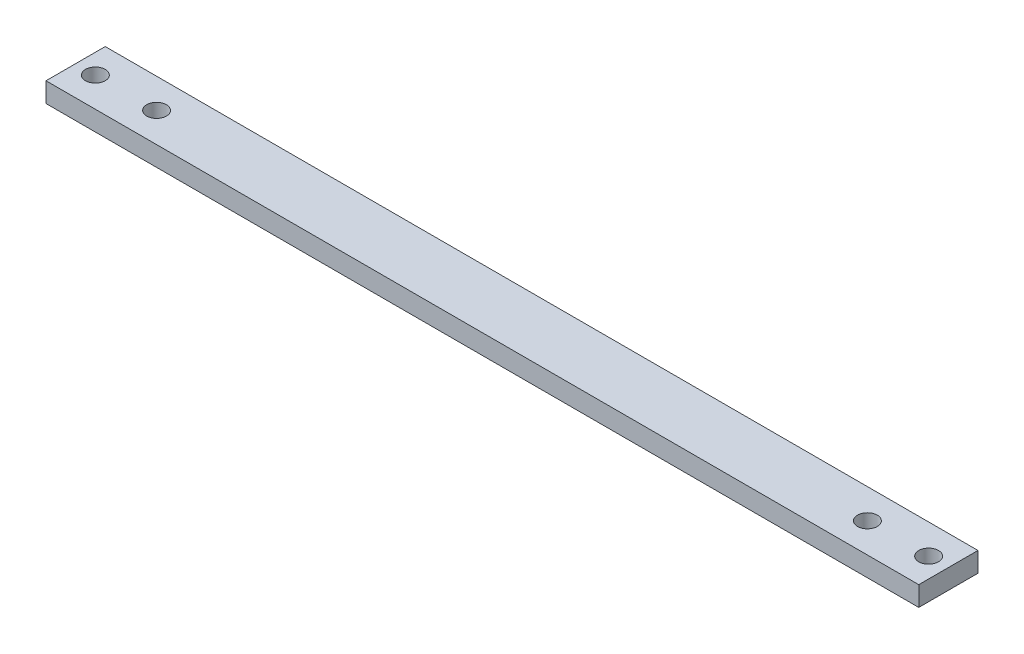
from build123d import *

# Parameters (mm, degrees)
SKETCH1_W           = 221
SKETCH1_H           = 15
SKETCH1_R           = 2.5
BOSS_EXTRUDE1_DEPTH = 5


with BuildPart() as part:
    # Sketch1 → Boss-Extrude1 (new body)
    with BuildSketch(Plane(origin=(0, 0, 0), x_dir=(1, 0, 0), z_dir=(0, 1, 0))):
        Rectangle(SKETCH1_W, SKETCH1_H)
        with Locations((105.5, 0)):
            Circle(SKETCH1_R, mode=Mode.SUBTRACT)
        with Locations((90, 0)):
            Circle(SKETCH1_R, mode=Mode.SUBTRACT)
        with Locations((-105.5, 0)):
            Circle(SKETCH1_R, mode=Mode.SUBTRACT)
        with Locations((-90, 0)):
            Circle(SKETCH1_R, mode=Mode.SUBTRACT)
    extrude(amount=BOSS_EXTRUDE1_DEPTH)


solid = part.part
